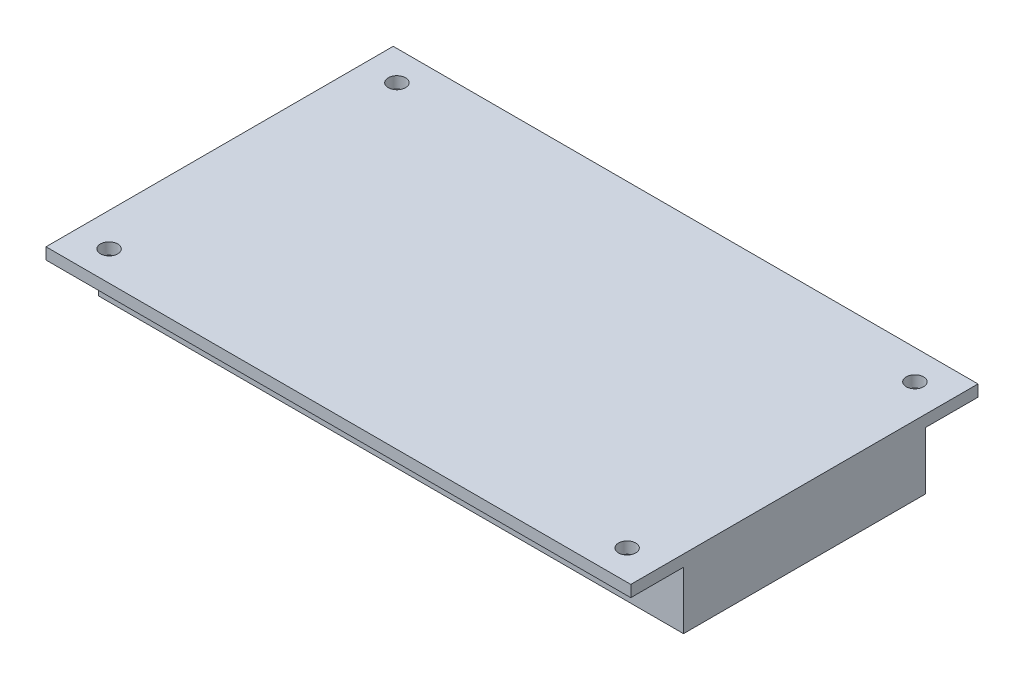
from build123d import *

# Parameters (mm, degrees)
SKETCH1_W           = 101.6
SKETCH1_H           = 60.325
BOSS_EXTRUDE1_DEPTH = 12
SKETCH2_W           = 9.1625
SKETCH2_H           = 10
CUT_EXTRUDE1_DEPTH  = 102.6
SKETCH3_R           = 1.5
CUT_EXTRUDE2_DEPTH  = 13


with BuildPart() as part:
    # Sketch1 → Boss-Extrude1 (new body)
    with BuildSketch(Plane(origin=(0, 0, 0), x_dir=(1, 0, 0), z_dir=(0, 1, 0))):
        Rectangle(SKETCH1_W, SKETCH1_H)
    extrude(amount=BOSS_EXTRUDE1_DEPTH)

    # Sketch2 → Cut-Extrude1 (cut, through all)
    with BuildSketch(Plane(origin=(50.8, 0, 0), x_dir=(0, 0, -1), z_dir=(1, 0, 0))):
        with Locations((-25.58125, 5)):
            Rectangle(SKETCH2_W, SKETCH2_H)
        with Locations((25.58125, 5)):
            Rectangle(SKETCH2_W, SKETCH2_H)
    extrude(amount=-CUT_EXTRUDE1_DEPTH, mode=Mode.SUBTRACT)

    # Sketch3 → Cut-Extrude2 (cut, through all)
    with BuildSketch(Plane(origin=(0, 12, 0), x_dir=(1, 0, 0), z_dir=(0, 1, 0))):
        with Locations((-45, 25)):
            Circle(SKETCH3_R)
        with Locations((-45, -25)):
            Circle(SKETCH3_R)
        with Locations((45, -25)):
            Circle(SKETCH3_R)
        with Locations((45, 25)):
            Circle(SKETCH3_R)
    extrude(amount=-CUT_EXTRUDE2_DEPTH, mode=Mode.SUBTRACT)


solid = part.part
